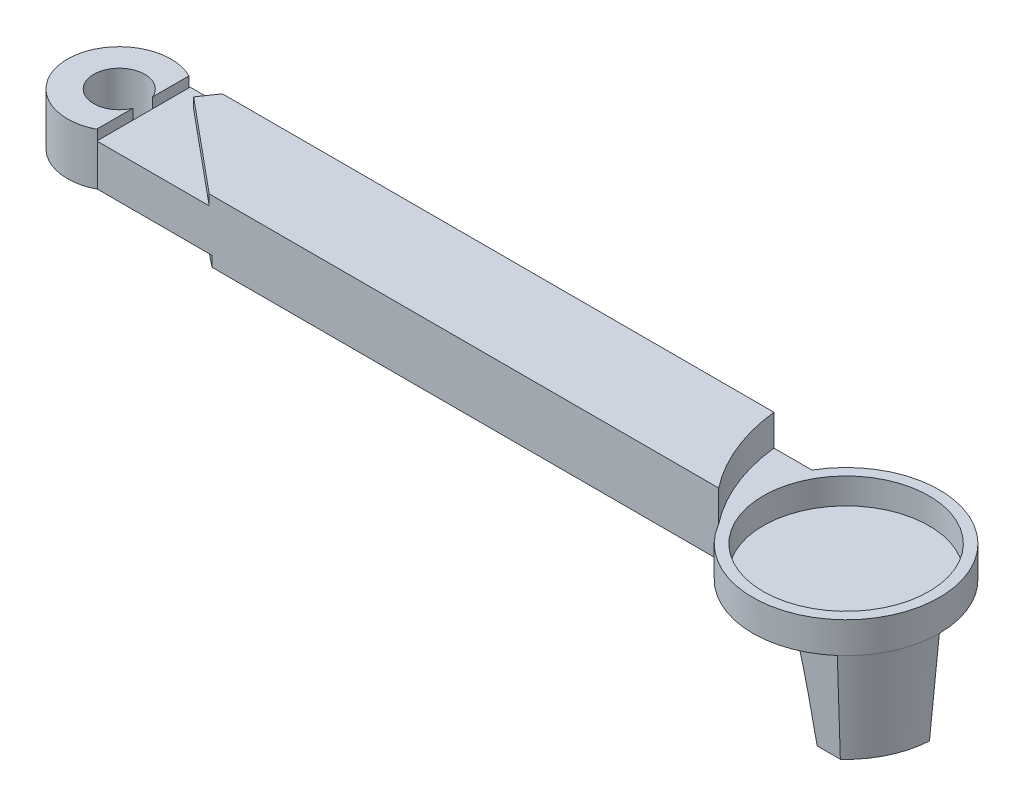
from build123d import *

# Parameters (mm, degrees)
BOSS_EXTRUDE1_DEPTH      = 5.999999938
SKETCH3_R                = 9
CUT_EXTRUDE1_DEPTH       = 3
CUT_EXTRUDE5_DEPTH       = 1
CUT_EXTRUDE5_DEPTH_BACK  = 3
EXTRUDE_THIN3_DEPTH      = 5.999999938
CUT_EXTRUDE9_DEPTH       = 1
CUT_EXTRUDE10_DEPTH      = 1
CUT_EXTRUDE10_DEPTH_BACK = 1
BOSS_EXTRUDE3_DEPTH      = 9
BOSS_EXTRUDE3_DRAFT      = 3
SKETCH14_R               = 8
CUT_EXTRUDE13_DEPTH      = 2.5
CUT_EXTRUDE15_DEPTH      = 10
CUT_EXTRUDE15_DEPTH_BACK = 1.000000032


with BuildPart() as part:
    # Sketch2 → Boss-Extrude1 (new body)
    with BuildSketch(Plane(origin=(0, 0, 0), x_dir=(1, 0, 0), z_dir=(0, 1, 0))):
        with BuildLine():
            Line((0, 0), (60, 0))
            ThreePointArc((60, 0), (76.794228634, 4.5), (60, 9))
            Line((60, 9), (0, 9))
            Line((0, 9), (0, 0))
        make_face()
    extrude(amount=BOSS_EXTRUDE1_DEPTH)

    # Sketch3 → Cut-Extrude1 (cut)
    with BuildSketch(Plane(origin=(0, 5.999999938, 0), x_dir=(1, 0, 0), z_dir=(0, 1, 0))):
        with Locations((67.794228634, 4.5)):
            Circle(SKETCH3_R)
    extrude(amount=-CUT_EXTRUDE1_DEPTH, mode=Mode.SUBTRACT)

    # Sketch5 → Cut-Extrude5 (cut, two sides)
    with BuildSketch(Plane(origin=(0, 5.999999938, 0), x_dir=(1, 0, 0), z_dir=(0, 1, 0))) as cut_extrude5_sk:
        with BuildLine():
            Line((141.885159374, -104.803724525), (60, 0))
            ThreePointArc((60, 0), (57.540129042, 4.245085458), (56.330788983, 9))
            Line((56.330788983, 9), (41.599359793, 141.181636372))
            Line((41.599359793, 141.181636372), (287.915588972, 241.602327681))
            Line((287.915588972, 241.602327681), (388.201388554, -4.383033215))
            Line((388.201388554, -4.383033215), (141.885159374, -104.803724525))
        make_face()
    extrude(amount=CUT_EXTRUDE5_DEPTH, mode=Mode.SUBTRACT)
    extrude(cut_extrude5_sk.sketch, amount=-CUT_EXTRUDE5_DEPTH_BACK, mode=Mode.SUBTRACT)

    # Sketch6 → Extrude-Thin3 (add)
    with BuildSketch(Plane(origin=(0, 5.999999938, 0), x_dir=(1, 0, 0), z_dir=(0, 1, 0))):
        with BuildLine():
            ThreePointArc((2.566768688, 3.148851961), (-7.252946342, 4.805124242), (2.704294257, 4.958097373))
            Line((2.704294257, 4.958097373), (0.178709714, 4.68787022))
            ThreePointArc((0.178709714, 4.68787022), (-4.720252661, 4.61260744), (0.111047134, 3.797721478))
            Line((0.111047134, 3.797721478), (2.566768688, 3.148851961))
        make_face()
    extrude(amount=-EXTRUDE_THIN3_DEPTH)

    # Sketch7 → Cut-Extrude9 (cut)
    with BuildSketch(Plane(origin=(0, 5.999999938, 0), x_dir=(1, 0, 0), z_dir=(0, 1, 0))):
        Polygon((0, 0), (0, 9), (10.83654063, 0), align=None)
    extrude(amount=-CUT_EXTRUDE9_DEPTH, mode=Mode.SUBTRACT)

    # Sketch8 → Cut-Extrude10 (cut, two sides)
    with BuildSketch(Plane(origin=(0, 5.999999938, 0), x_dir=(1, 0, 0), z_dir=(0, 1, 0))) as cut_extrude10_sk:
        Polygon((0, 9), (1.982929041, 7.353131135), (3.117751909, 9), align=None)
    extrude(amount=CUT_EXTRUDE10_DEPTH, mode=Mode.SUBTRACT)
    extrude(cut_extrude10_sk.sketch, amount=-CUT_EXTRUDE10_DEPTH_BACK, mode=Mode.SUBTRACT)


with BuildPart() as boss_extrude3_tool:
    # Sketch9 → Boss-Extrude3 (with draft: the straight prism first)
    with BuildSketch(Plane(origin=(0, 0, 0), x_dir=(-1, 0, 0), z_dir=(0, -1, 0))):
        with BuildLine():
            Line((-73.720761097, -2.273198134), (-69.720761097, -2.273198134))
            ThreePointArc((-69.720761097, -2.273198134), (-72.492846156, 0.552836778), (-72.794228634, 4.5))
            Line((-72.794228634, 4.5), (-76.794228634, 4.5))
            ThreePointArc((-76.794228634, 4.5), (-75.989922386, 0.781048008), (-73.720761097, -2.273198134))
        make_face()
    extrude(amount=BOSS_EXTRUDE3_DEPTH)
    # Boss-Extrude3: the draft: its side faces are tilted about the plane it starts from
    boss_extrude3_sides = [boss_extrude3_tool.faces().sort_by_distance(p)[0] for p in [
        (72.492846156, -4.5, -0.552836778),
        (74.794228634, -4.5, -4.5),
        (75.989922386, -4.5, -0.781048008),
        (71.720761097, -4.5, 2.273198134),
    ]]
    draft(boss_extrude3_sides, Plane(origin=(0, 0, 0), x_dir=(-1, 0, 0), z_dir=(0, -1, 0)), BOSS_EXTRUDE3_DRAFT)


with BuildPart() as part_1:
    add(part.part)

    # Boss-Extrude3: add boss_extrude3_tool
    add(boss_extrude3_tool.part)

    # Sketch14 → Cut-Extrude13 (cut)
    with BuildSketch(Plane(origin=(0, 2.999999938, 0), x_dir=(1, 0, 0), z_dir=(0, 1, 0))):
        with Locations((67.794228634, 4.5)):
            Circle(SKETCH14_R)
    extrude(amount=-CUT_EXTRUDE13_DEPTH, mode=Mode.SUBTRACT)

    # Sketch16 → Cut-Extrude15 (cut, two sides)
    with BuildSketch(Plane(origin=(0, 0, 0), x_dir=(-1, 0, 0), z_dir=(0, -1, 0))) as cut_extrude15_sk:
        Polygon((129.561472715, 112.505246853), (0, 8.882522618), (-11.105987806, 0), (-140.667460521, -103.622724235), (66.57798795, -362.745669665), (336.806921186, -146.617698577), align=None)
    extrude(amount=CUT_EXTRUDE15_DEPTH, mode=Mode.SUBTRACT)
    extrude(cut_extrude15_sk.sketch, amount=-CUT_EXTRUDE15_DEPTH_BACK, mode=Mode.SUBTRACT)


solid = part_1.part
